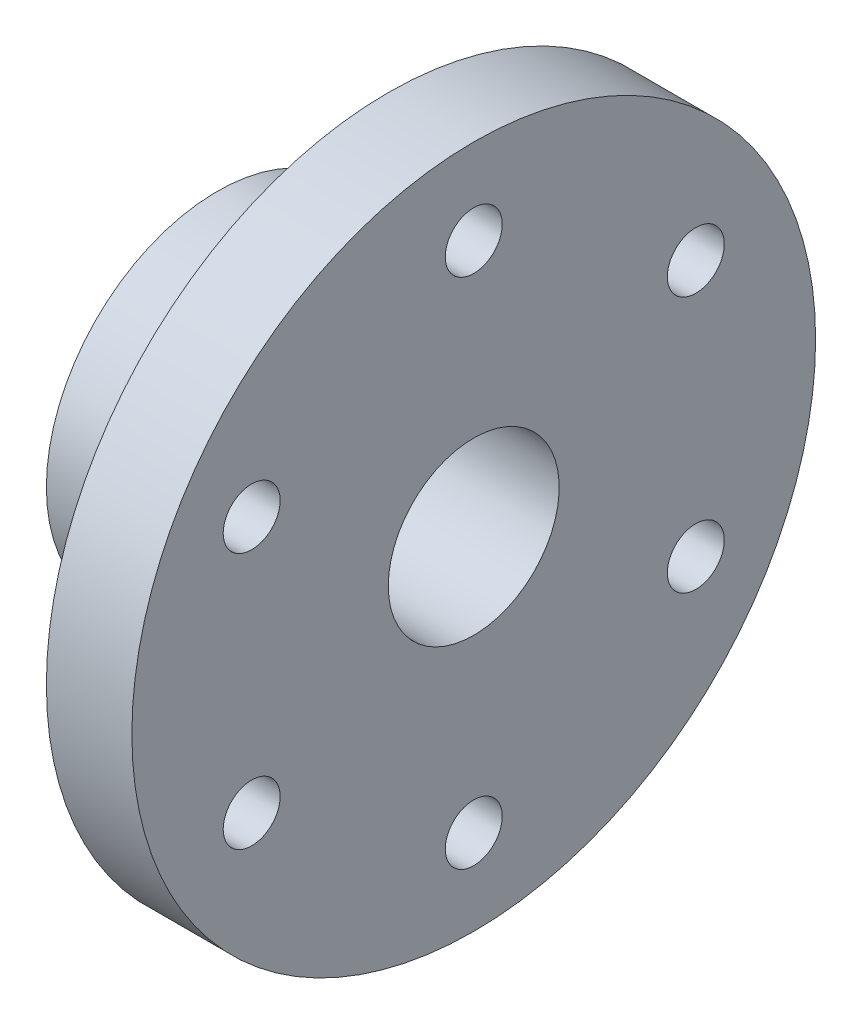
from build123d import *

# Parameters (mm, degrees)
SKETCH2_R          = 4
CUT_EXTRUDE1_DEPTH = 12
CUT_EXTRUDE2_REACH = 74
SKETCH3_R          = 4


with BuildPart() as part:
    # Sketch1 → Revolve1 (revolve)
    with BuildSketch(Plane.XY):
        Polygon((-25.700460829, 12), (-25.700460829, 24), (-1.700460829, 24), (-1.700460829, 48), (10.299539171, 48), (10.299539171, 12), align=None)
    revolve(axis=Axis((-11.612903226, 0, 0), (1, 0, 0)))

    # Sketch2 → Cut-Extrude1 (cut)
    with BuildSketch(Plane.ZY.offset(1.700460829)):
        with Locations((0, 36)):
            Circle(SKETCH2_R)
        with Locations((31.176914536, 18)):
            Circle(SKETCH2_R)
        with Locations((31.176914536, -18)):
            Circle(SKETCH2_R)
        with Locations((0, -36)):
            Circle(SKETCH2_R)
        with Locations((-31.176914536, -18)):
            Circle(SKETCH2_R)
        with Locations((-31.176914536, 18)):
            Circle(SKETCH2_R)
    extrude(amount=-CUT_EXTRUDE1_DEPTH, mode=Mode.SUBTRACT)

    # Sketch3 → Cut-Extrude2 (cut, up to next)
    with BuildSketch(Plane.XY.offset(24), mode=Mode.PRIVATE) as cut_extrude2_sk1:
        with Locations((-13.700460829, 0)):
            Circle(SKETCH3_R)
    cut_extrude2_tool1 = extrude(cut_extrude2_sk1.sketch, amount=-CUT_EXTRUDE2_REACH, mode=Mode.PRIVATE) & part.part
    add(cut_extrude2_tool1.solids().sort_by_distance((-13.700461, 0, 24))[0], mode=Mode.SUBTRACT)


solid = part.part
